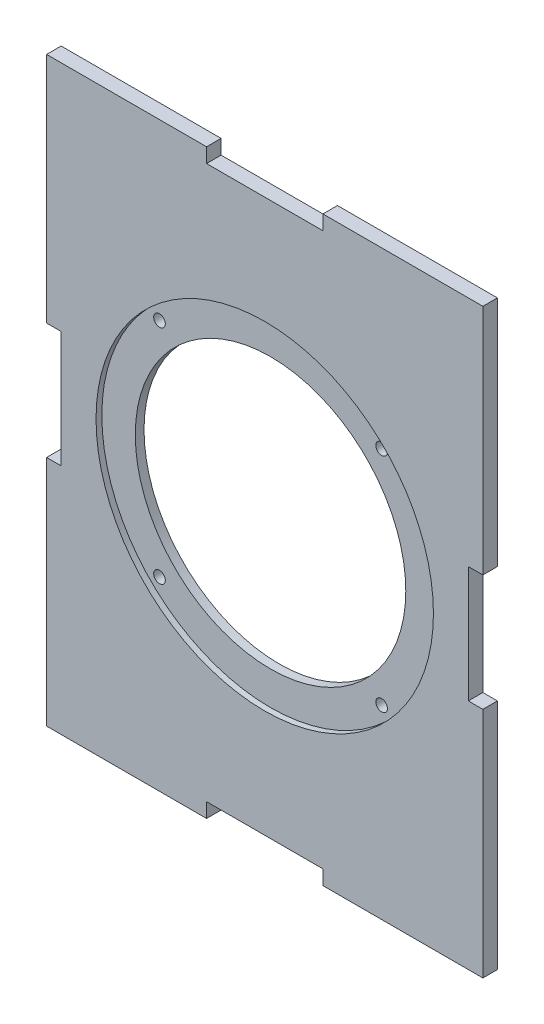
from build123d import *

# Parameters (mm, degrees)
CROQUIS1_W              = 150
CROQUIS1_H              = 200
CROQUIS1_R              = 46.5
CROQUIS1_R_2            = 2
SALIENTE_EXTRUIR1_DEPTH = 5
CROQUIS2_R              = 58
CORTAR_EXTRUIR1_DEPTH   = 2
CORTAR_EXTRUIR2_START   = -5
CROQUIS3_W              = 40
CROQUIS3_H              = 5
CROQUIS3_W_2            = 5
CROQUIS3_H_2            = 40
CORTAR_EXTRUIR2_DEPTH   = 5


with BuildPart() as part:
    # Croquis1 → Saliente-Extruir1 (new body)
    with BuildSketch(Plane.XY):
        Rectangle(CROQUIS1_W, CROQUIS1_H)
        Circle(CROQUIS1_R, mode=Mode.SUBTRACT)
        with Locations((-38.183766184, 38.183766184)):
            Circle(CROQUIS1_R_2, mode=Mode.SUBTRACT)
        with Locations((38.183766184, 38.183766184)):
            Circle(CROQUIS1_R_2, mode=Mode.SUBTRACT)
        with Locations((38.183766184, -38.183766184)):
            Circle(CROQUIS1_R_2, mode=Mode.SUBTRACT)
        with Locations((-38.183766184, -38.183766184)):
            Circle(CROQUIS1_R_2, mode=Mode.SUBTRACT)
    extrude(amount=SALIENTE_EXTRUIR1_DEPTH)

    # Croquis2 → Cortar-Extruir1 (cut)
    with BuildSketch(Plane.XY.offset(5)):
        Circle(CROQUIS2_R)
    extrude(amount=-CORTAR_EXTRUIR1_DEPTH, mode=Mode.SUBTRACT)

    # Croquis3 → Cortar-Extruir2 (cut)
    with BuildSketch(Plane.XY.offset(5).offset(CORTAR_EXTRUIR2_START)):
        with Locations((0, 97.5)):
            Rectangle(CROQUIS3_W, CROQUIS3_H)
        with Locations((0, -97.5)):
            Rectangle(CROQUIS3_W, CROQUIS3_H)
        with Locations((-72.5, 0)):
            Rectangle(CROQUIS3_W_2, CROQUIS3_H_2)
        with Locations((72.5, 0)):
            Rectangle(CROQUIS3_W_2, CROQUIS3_H_2)
    extrude(amount=CORTAR_EXTRUIR2_DEPTH, mode=Mode.SUBTRACT)


solid = part.part
